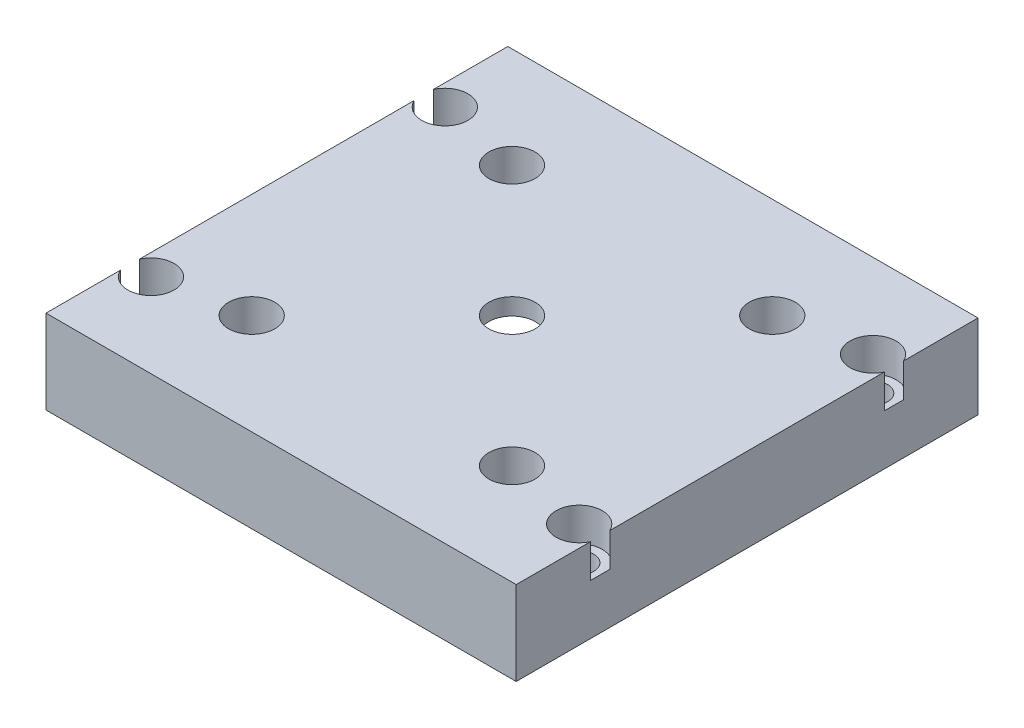
from build123d import *

# Parameters (mm, degrees)
SKETCH2_W           = 56
SKETCH2_H           = 55
BOSS_EXTRUDE1_DEPTH = 5
SKETCH4_R           = 11.5
CUT_EXTRUDE1_DEPTH  = 3
SKETCH5_R           = 1.75
CUT_EXTRUDE3_DEPTH  = 54
SKETCH6_W           = 56
SKETCH6_H           = 55
SKETCH6_W_2         = 46
SKETCH6_H_2         = 45
BOSS_EXTRUDE2_DEPTH = 5
SKETCH3_R           = 2.75
SKETCH3_R_2         = 1.75
CUT_EXTRUDE2_DEPTH  = 12
SKETCH5_2_R         = 1.75
CUT_EXTRUDE4_DEPTH  = 33
SKETCH7_R           = 2.75
CUT_EXTRUDE5_DEPTH  = 4


with BuildPart() as part:
    # Sketch2 → Boss-Extrude1 (new body)
    with BuildSketch(Plane(origin=(0, 0, 0), x_dir=(1, 0, 0), z_dir=(0, 1, 0))):
        Rectangle(SKETCH2_W, SKETCH2_H)
    extrude(amount=BOSS_EXTRUDE1_DEPTH)

    # Sketch4 → Cut-Extrude1 (cut)
    with BuildSketch(Plane.XZ):
        Circle(SKETCH4_R)
    extrude(amount=-CUT_EXTRUDE1_DEPTH, mode=Mode.SUBTRACT)

    # Sketch5 → Cut-Extrude3 (cut)
    with BuildSketch(Plane(origin=(0, 5, 0), x_dir=(1, 0, 0), z_dir=(0, 1, 0))):
        with Locations((-25.5, 17.5)):
            Circle(SKETCH5_R)
        with Locations((25.5, -17.5)):
            Circle(SKETCH5_R)
        with Locations((-25.5, -17.5)):
            Circle(SKETCH5_R)
        with Locations((25.5, 17.5)):
            Circle(SKETCH5_R)
    extrude(amount=-CUT_EXTRUDE3_DEPTH, mode=Mode.SUBTRACT)

    # Sketch6 → Boss-Extrude2 (add)
    with BuildSketch(Plane.XZ):
        Rectangle(SKETCH6_W, SKETCH6_H)
        Rectangle(SKETCH6_W_2, SKETCH6_H_2, mode=Mode.SUBTRACT)
    extrude(amount=BOSS_EXTRUDE2_DEPTH)

    # Sketch3 → Cut-Extrude2 (cut)
    with BuildSketch(Plane(origin=(0, 5, 0), x_dir=(1, 0, 0), z_dir=(0, 1, 0))):
        Circle(SKETCH3_R)
        with Locations((-15.5, 15.5)):
            Circle(SKETCH3_R_2)
        with Locations((15.5, 15.5)):
            Circle(SKETCH3_R_2)
        with Locations((15.5, -15.5)):
            Circle(SKETCH3_R_2)
        with Locations((-15.5, -15.5)):
            Circle(SKETCH3_R_2)
    extrude(amount=-CUT_EXTRUDE2_DEPTH, mode=Mode.SUBTRACT)

    # Sketch5_2 → Cut-Extrude4 (cut)
    with BuildSketch(Plane(origin=(0, 5, 0), x_dir=(1, 0, 0), z_dir=(0, 1, 0))):
        with Locations((-25.5, 17.5)):
            Circle(SKETCH5_2_R)
        with Locations((25.5, -17.5)):
            Circle(SKETCH5_2_R)
        with Locations((-25.5, -17.5)):
            Circle(SKETCH5_2_R)
        with Locations((25.5, 17.5)):
            Circle(SKETCH5_2_R)
    extrude(amount=-CUT_EXTRUDE4_DEPTH, mode=Mode.SUBTRACT)

    # Sketch7 → Cut-Extrude5 (cut)
    with BuildSketch(Plane(origin=(0, 5, 0), x_dir=(1, 0, 0), z_dir=(0, 1, 0))):
        with Locations((-15.5, 15.5)):
            Circle(SKETCH7_R)
        with Locations((15.5, 15.5)):
            Circle(SKETCH7_R)
        with Locations((15.5, -15.5)):
            Circle(SKETCH7_R)
        with Locations((-15.5, -15.5)):
            Circle(SKETCH7_R)
        with Locations((-25.5, 17.5)):
            Circle(SKETCH7_R)
        with Locations((-25.5, -17.5)):
            Circle(SKETCH7_R)
        with Locations((25.5, 17.5)):
            Circle(SKETCH7_R)
        with Locations((25.5, -17.5)):
            Circle(SKETCH7_R)
    extrude(amount=-CUT_EXTRUDE5_DEPTH, mode=Mode.SUBTRACT)


solid = part.part
